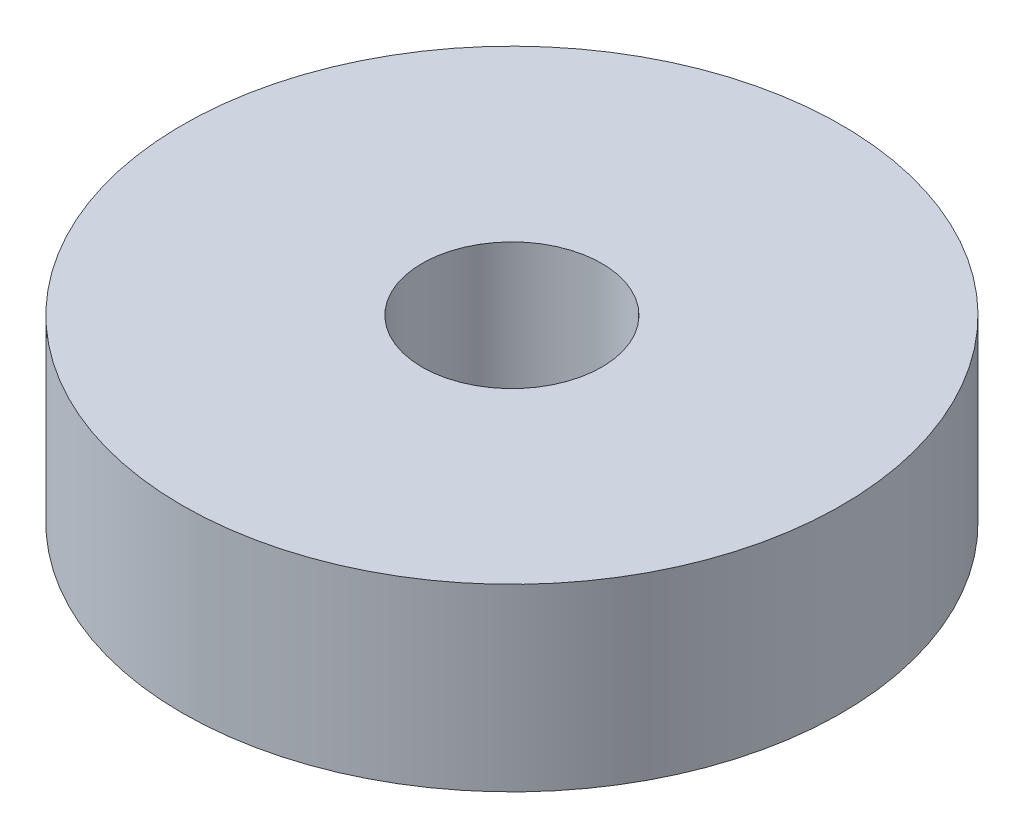
from build123d import *

# Parameters (mm, degrees)
SKETCH1_R           = 11
SKETCH1_R_2         = 3
BOSS_EXTRUDE1_DEPTH = 6


with BuildPart() as part:
    # Sketch1 → Boss-Extrude1 (new body)
    with BuildSketch(Plane(origin=(0, 0, 0), x_dir=(1, 0, 0), z_dir=(0, 1, 0))):
        Circle(SKETCH1_R)
        Circle(SKETCH1_R_2, mode=Mode.SUBTRACT)
    extrude(amount=BOSS_EXTRUDE1_DEPTH)


solid = part.part
